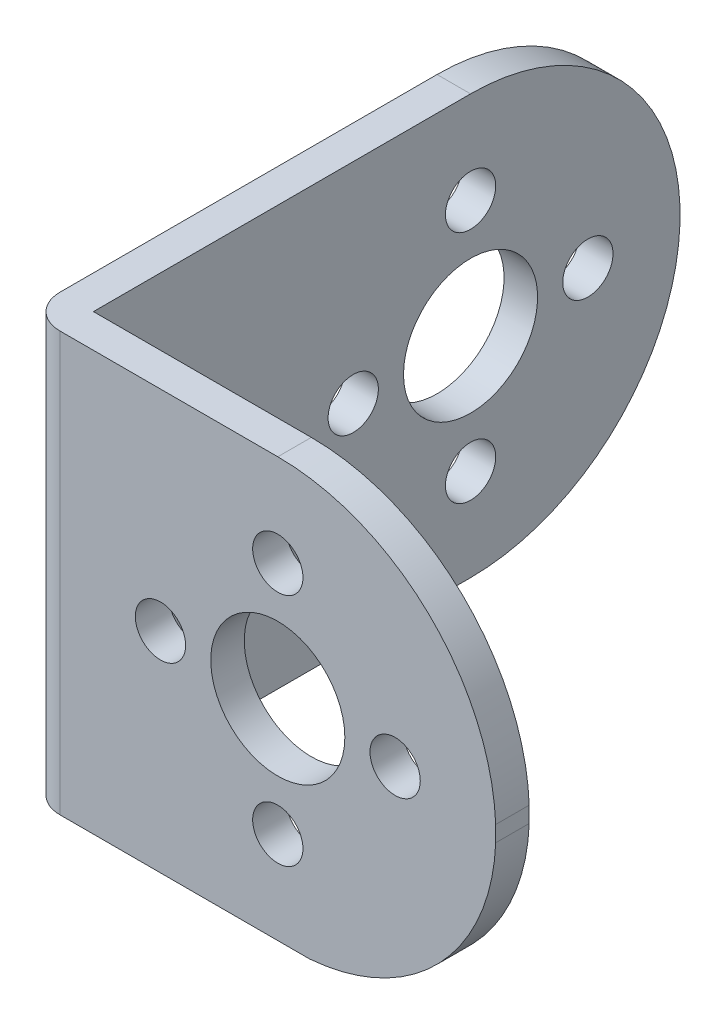
from build123d import *

# Parameters (mm, degrees)
ESTRUSIONE_ESTRUSIONE1_DEPTH = 25
RACCORDO1_R                  = 2
TAGLIO_ESTRUSIONE1_DEPTH     = 29
TAGLIO_ESTRUSIONE3_DEPTH     = 38
SCHIZZO6_R                   = 4
SCHIZZO6_R_2                 = 1.5
TAGLIO_ESTRUSIONE4_DEPTH     = 38
SCHIZZO7_R                   = 4
SCHIZZO7_R_2                 = 1.5
TAGLIO_ESTRUSIONE5_DEPTH     = 29


with BuildPart() as part:
    # Schizzo1 → Estrusione-Estrusione1 (new body)
    with BuildSketch(Plane(origin=(0, 0, 0), x_dir=(1, 0, 0), z_dir=(0, 1, 0))):
        Polygon((11.035530567, -4.481060606), (-16.964469433, -4.481060606), (-16.964469433, 32.518939394), (-14.964469433, 32.518939394), (-14.964469433, -2.481060606), (11.035530567, -2.481060606), align=None)
    extrude(amount=ESTRUSIONE_ESTRUSIONE1_DEPTH)

    # Raccordo1
    raccordo1_edges = [part.edges().sort_by_distance(p)[0] for p in [
        (-16.964469433, 12.5, 4.481060606),
    ]]
    fillet(raccordo1_edges, radius=RACCORDO1_R)

    # Schizzo2 → Taglio-Estrusione1 (cut, through all)
    with BuildSketch(Plane.ZY.offset(16.964469433)):
        with BuildLine():
            ThreePointArc((-20.018939394, 0), (-28.857774159, 3.661165235), (-32.518939394, 12.5))
            Line((-32.518939394, 12.5), (-32.518939394, 0))
            Line((-32.518939394, 0), (-20.018939394, 0))
        make_face()
        with BuildLine():
            Line((-20.018939394, 25), (-32.518939394, 25))
            Line((-32.518939394, 25), (-32.518939394, 12.5))
            ThreePointArc((-32.518939394, 12.5), (-28.857774159, 21.338834765), (-20.018939394, 25))
        make_face()
    extrude(amount=-TAGLIO_ESTRUSIONE1_DEPTH, mode=Mode.SUBTRACT)

    # Schizzo4 → Taglio-Estrusione3 (cut, through all)
    with BuildSketch(Plane.XY.offset(4.481060606)):
        with BuildLine():
            Line((11.035530567, 25), (-1.964469433, 25))
            ThreePointArc((-1.964469433, 25), (7.052874966, 21.368038174), (11.035530567, 12.5))
            Line((11.035530567, 12.5), (11.035530567, 25))
        make_face()
        with BuildLine():
            Line((11.035530567, 0), (11.035530567, 11.554155381))
            ThreePointArc((11.035530567, 11.554155381), (7.676890272, 3.665306442), (-0.074234222, 0))
            Line((-0.074234222, 0), (11.035530567, 0))
        make_face()
    extrude(amount=-TAGLIO_ESTRUSIONE3_DEPTH, mode=Mode.SUBTRACT)

    # Schizzo6 → Taglio-Estrusione4 (cut, through all)
    with BuildSketch(Plane.XY.offset(4.481060606)):
        with Locations((-1.964469433, 12.5)):
            Circle(SCHIZZO6_R)
        with Locations((-1.964469433, 19.5)):
            Circle(SCHIZZO6_R_2)
        with Locations((-1.964469433, 5.5)):
            Circle(SCHIZZO6_R_2)
        with Locations((5.035530567, 12.5)):
            Circle(SCHIZZO6_R_2)
        with Locations((-8.964469433, 12.5)):
            Circle(SCHIZZO6_R_2)
    extrude(amount=-TAGLIO_ESTRUSIONE4_DEPTH, mode=Mode.SUBTRACT)

    # Schizzo7 → Taglio-Estrusione5 (cut, through all)
    with BuildSketch(Plane.ZY.offset(16.964469433)):
        with Locations((-20.018939394, 12.5)):
            Circle(SCHIZZO7_R)
        with Locations((-27.018939394, 12.5)):
            Circle(SCHIZZO7_R_2)
        with Locations((-20.018939394, 19.5)):
            Circle(SCHIZZO7_R_2)
        with Locations((-20.018939394, 5.5)):
            Circle(SCHIZZO7_R_2)
        with Locations((-13.018939394, 12.5)):
            Circle(SCHIZZO7_R_2)
    extrude(amount=-TAGLIO_ESTRUSIONE5_DEPTH, mode=Mode.SUBTRACT)


solid = part.part
